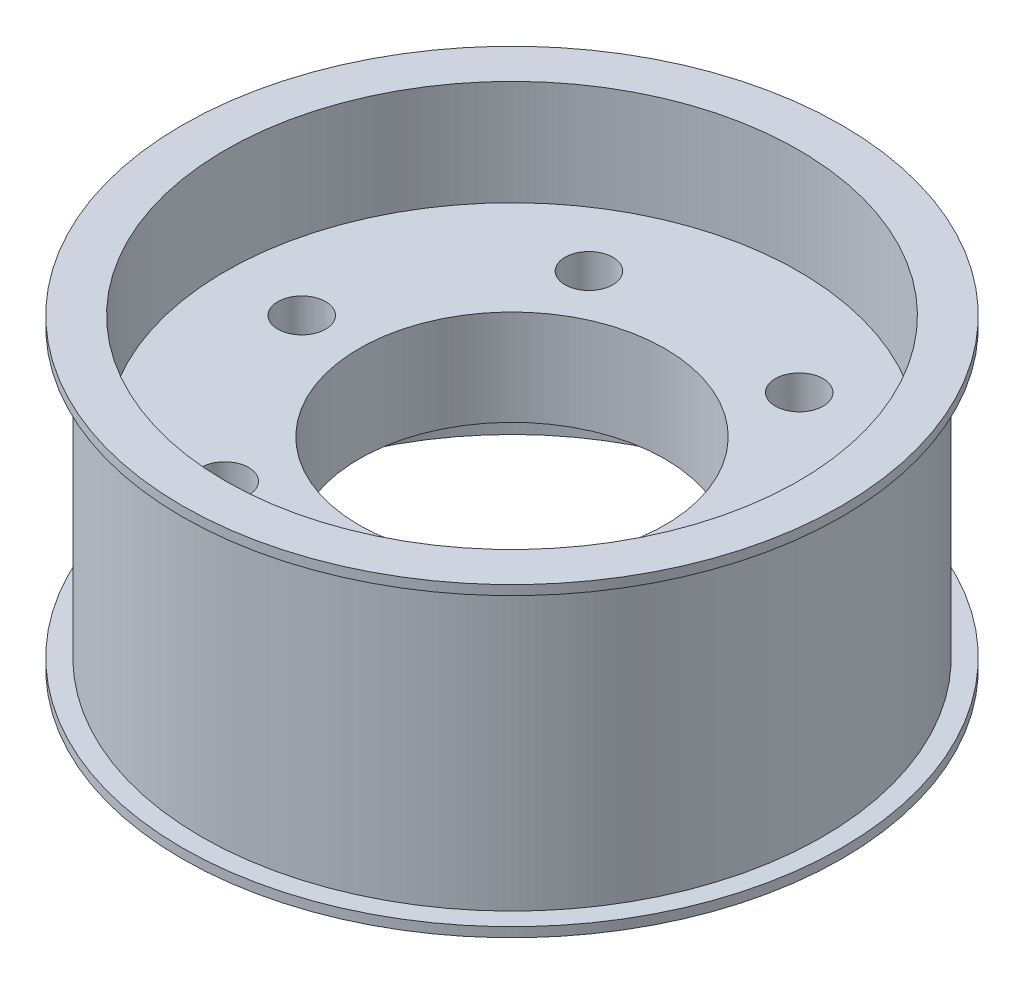
from build123d import *

# Parameters (mm, degrees)
SKETCH2_R          = 1.25
SKETCH2_R_2        = 8
CUT_EXTRUDE1_DEPTH = 10


with BuildPart() as part:
    # Sketch1 → Revolve1 (revolve)
    with BuildSketch(Plane.XY):
        Polygon((15, 8), (17.25, 8), (17.25, 7.5), (16.25, 7.5), (16.25, -7.5), (17.25, -7.5), (17.25, -8), (15, -8), (15, -2.5), (0, -2.5), (0, 2.5), (15, 2.5), align=None)
    revolve(axis=Axis((0, 8.982990787, 0), (0, -1, 0)))

    # Sketch2 → Cut-Extrude1 (cut, symmetric)
    with BuildSketch(Plane(origin=(0, 2.5, 0), x_dir=(1, 0, 0), z_dir=(0, 1, 0))):
        with Locations((11, 0)):
            Circle(SKETCH2_R)
        with Locations((5.5, -9.526279442)):
            Circle(SKETCH2_R)
        with Locations((-5.5, -9.526279442)):
            Circle(SKETCH2_R)
        with Locations((-11, 0)):
            Circle(SKETCH2_R)
        with Locations((-5.5, 9.526279442)):
            Circle(SKETCH2_R)
        with Locations((5.5, 9.526279442)):
            Circle(SKETCH2_R)
        Circle(SKETCH2_R_2)
    extrude(amount=CUT_EXTRUDE1_DEPTH, both=True, mode=Mode.SUBTRACT)


solid = part.part
